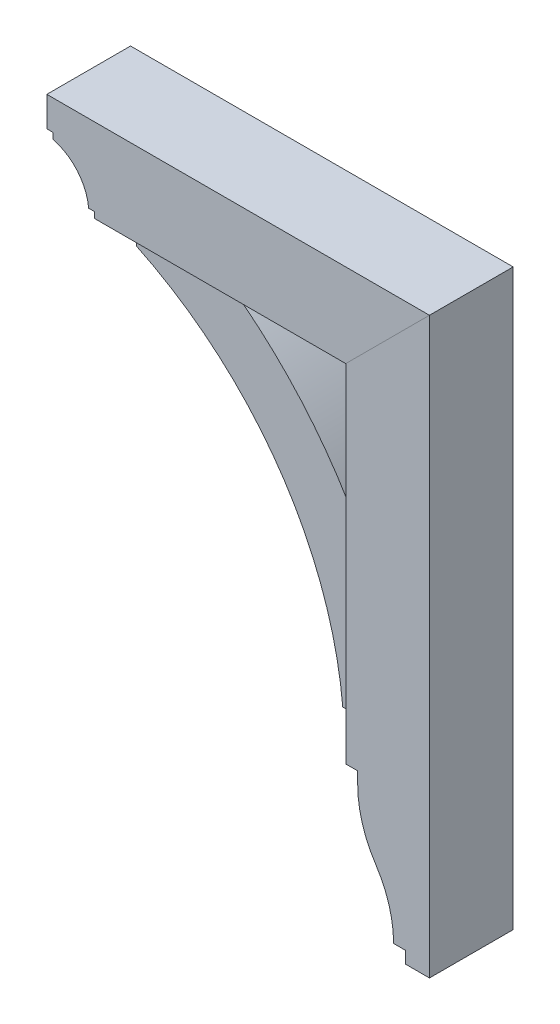
from build123d import *

# Parameters (mm, degrees)
BOSS_EXTRUDE1_DEPTH = 44.45
BOSS_EXTRUDE2_DEPTH = 31.75
BOSS_EXTRUDE3_DEPTH = 44.45


with BuildPart() as part:
    # Sketch1 → Boss-Extrude1 (new body, symmetric)
    with BuildSketch(Plane.XY):
        with BuildLine():
            Line((-76.968776984, 235.585), (-76.968776984, 241.935))
            Line((-76.968776984, 241.935), (-83.318776984, 241.935))
            Line((-83.318776984, 241.935), (-83.318776984, 273.685))
            Line((-83.318776984, 273.685), (323.081223016, 273.685))
            Line((323.081223016, 273.685), (234.181223016, 184.785))
            Line((234.181223016, 184.785), (-32.518776984, 184.785))
            Line((-32.518776984, 184.785), (-32.518776984, 191.135))
            Line((-32.518776984, 191.135), (-38.868776984, 191.135))
            ThreePointArc((-38.868776984, 191.135), (-50.860423906, 219.410016924), (-76.968776984, 235.585))
        make_face()
    extrude(amount=BOSS_EXTRUDE1_DEPTH, both=True)


with BuildPart() as body_2:
    # Sketch1_3 → Boss-Extrude2 (new body, symmetric)
    with BuildSketch(Plane.XY):
        with BuildLine():
            ThreePointArc((234.181223016, 27.6225), (174.235964773, 114.210379121), (96.068723016, 184.785))
            Line((96.068723016, 184.785), (-0.768776984, 184.785))
            Line((-0.768776984, 184.785), (-0.768776984, 168.91))
            ThreePointArc((-0.768776984, 168.91), (150.352815584, 40.730352396), (218.306223016, -145.415))
            Line((218.306223016, -145.415), (234.181223016, -145.415))
            Line((234.181223016, -145.415), (234.181223016, 27.6225))
        make_face()
    extrude(amount=BOSS_EXTRUDE2_DEPTH, both=True)


with BuildPart() as body_3:
    # Sketch1_4 → Boss-Extrude3 (new body, symmetric)
    with BuildSketch(Plane.XY):
        with BuildLine():
            Line((323.081223016, -335.915), (323.081223016, 273.685))
            Line((323.081223016, 273.685), (234.181223016, 184.785))
            Line((234.181223016, 184.785), (234.181223016, -183.515))
            Line((234.181223016, -183.515), (246.881223016, -183.515))
            Line((246.881223016, -183.515), (246.881223016, -196.215))
            ThreePointArc((246.881223016, -196.215), (251.768629387, -229.515028089), (266.018608337, -260.006284404))
            ThreePointArc((266.018608337, -260.006284404), (280.138450492, -290.219081757), (284.981223016, -323.215))
            Line((284.981223016, -323.215), (297.681223016, -323.215))
            Line((297.681223016, -323.215), (297.681223016, -335.915))
            Line((297.681223016, -335.915), (323.081223016, -335.915))
        make_face()
    extrude(amount=BOSS_EXTRUDE3_DEPTH, both=True)


solid = Compound([part.part, body_2.part, body_3.part])
